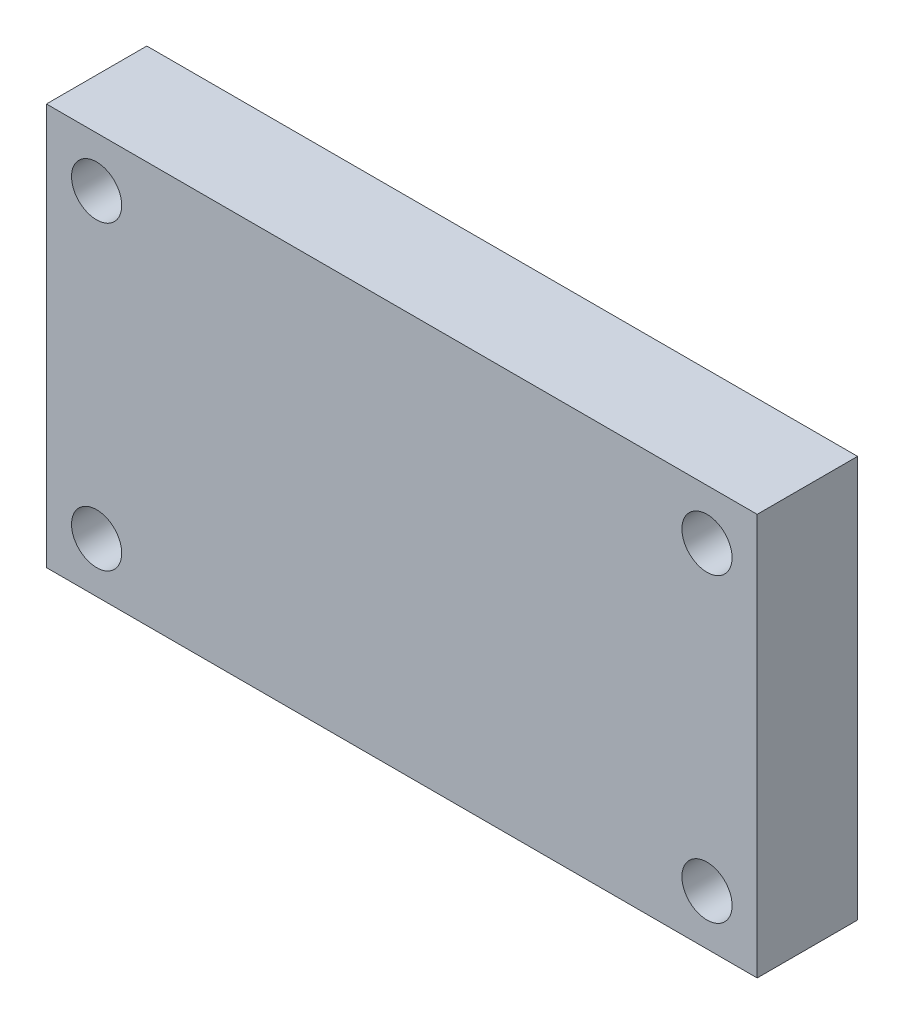
from build123d import *

# Parameters (mm, degrees)
SKETCH1_W           = 5
SKETCH1_H           = 5
SKETCH1_R           = 1.25
BOSS_EXTRUDE1_DEPTH = 5


with BuildPart() as part:
    # Sketch1 → Boss-Extrude1 (new body)
    with BuildSketch(Plane.XY):
        Polygon((30.4, 0), (5, 0), (5, -5), (0, -5), (0, -15), (5, -15), (5, -20), (30.4, -20), (30.4, -15), (35.4, -15), (35.4, -5), (30.4, -5), align=None)
        with Locations((2.5, -2.5)):
            Rectangle(SKETCH1_W, SKETCH1_H)
        with Locations((2.5, -2.5)):
            Circle(SKETCH1_R, mode=Mode.SUBTRACT)
        with Locations((32.9, -2.5)):
            Rectangle(SKETCH1_W, SKETCH1_H)
        with Locations((32.9, -2.5)):
            Circle(SKETCH1_R, mode=Mode.SUBTRACT)
        with Locations((32.9, -17.5)):
            Rectangle(SKETCH1_W, SKETCH1_H)
        with Locations((32.9, -17.5)):
            Circle(SKETCH1_R, mode=Mode.SUBTRACT)
        with Locations((2.5, -17.5)):
            Rectangle(SKETCH1_W, SKETCH1_H)
        with Locations((2.5, -17.5)):
            Circle(SKETCH1_R, mode=Mode.SUBTRACT)
    extrude(amount=BOSS_EXTRUDE1_DEPTH)


solid = part.part
